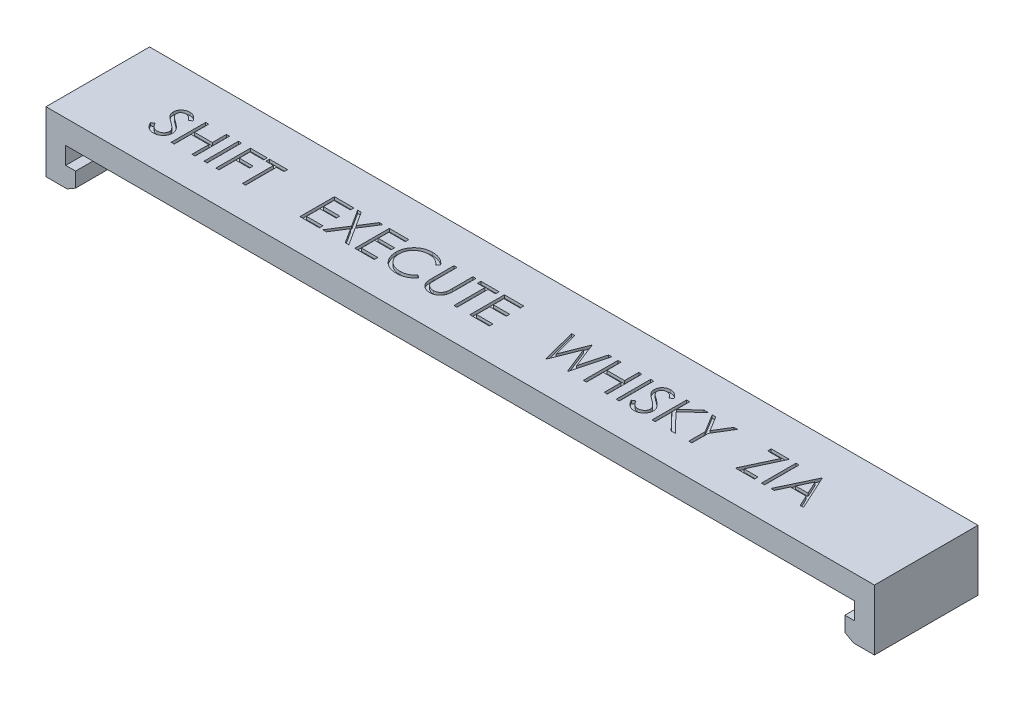
from build123d import *

# Parameters (mm, degrees)
SKETCH1_W             = 80
SKETCH1_H             = 10.5
BOSS_EXTRUDE1_DEPTH   = 2.4
SKETCH2_W             = 10.5
SKETCH2_H             = 4.15
BOSS_EXTRUDE2_DEPTH   = 2
SKETCH3_W             = 10.5
SKETCH3_H             = 4.15
BOSS_EXTRUDE3_DEPTH   = 2
SKETCH4_W             = 3
SKETCH4_H             = 10.5
BOSS_EXTRUDE4_DEPTH   = 2
CHAMFER1_SIZE         = 0.5
CHAMFER1_SIZE2        = 0.866025404
CHAMFER1_PART_2_SIZE  = 0.5
CHAMFER1_PART_2_SIZE2 = 0.866025404
SKETCH5_W             = 80
SKETCH5_H             = 6.4
CUT_EXTRUDE1_DEPTH    = 1.7
SKETCH6_W             = 0.314102564
SKETCH6_H             = 3.5
CUT_EXTRUDE2_DEPTH    = 0.3


with BuildPart() as part:
    # Sketch1 → Boss-Extrude1 (new body)
    with BuildSketch(Plane(origin=(0, 0, 0), x_dir=(1, 0, 0), z_dir=(0, 1, 0))):
        Rectangle(SKETCH1_W, SKETCH1_H)
    extrude(amount=BOSS_EXTRUDE1_DEPTH)

    # Sketch2 → Boss-Extrude2 (add)
    with BuildSketch(Plane(origin=(40, 0, 0), x_dir=(0, 0, -1), z_dir=(1, 0, 0))):
        with Locations((0, 0.325)):
            Rectangle(SKETCH2_W, SKETCH2_H)
    extrude(amount=BOSS_EXTRUDE2_DEPTH)

    # Sketch3 → Boss-Extrude3 (add)
    with BuildSketch(Plane.ZY.offset(40)):
        with Locations((0, 0.325)):
            Rectangle(SKETCH3_W, SKETCH3_H)
    extrude(amount=BOSS_EXTRUDE3_DEPTH)

    # Sketch4 → Boss-Extrude4 (add)
    with BuildSketch(Plane.XZ.offset(1.75)):
        with Locations((-40.5, 0)):
            Rectangle(SKETCH4_W, SKETCH4_H)
        with Locations((40.5, 0)):
            Rectangle(SKETCH4_W, SKETCH4_H)
    extrude(amount=BOSS_EXTRUDE4_DEPTH)

    # Chamfer1
    chamfer1_edges = [part.edges().sort_by_distance(p)[0] for p in [
        (-39, -3.75, 0),
    ]]
    chamfer1_side = [part.faces().sort_by_distance(p)[0] for p in [
        (-39, -2.75, 0),
    ]]
    chamfer(chamfer1_edges, length=CHAMFER1_SIZE, length2=CHAMFER1_SIZE2, reference=chamfer1_side[0])

    # Chamfer1 part 2
    chamfer1_part_2_edges = [part.edges().sort_by_distance(p)[0] for p in [
        (39, -3.75, 0),
    ]]
    chamfer1_part_2_side = [part.faces().sort_by_distance(p)[0] for p in [
        (39, -2.75, 0),
    ]]
    chamfer(chamfer1_part_2_edges, length=CHAMFER1_PART_2_SIZE, length2=CHAMFER1_PART_2_SIZE2, reference=chamfer1_part_2_side[0])

    # Sketch5 → Cut-Extrude1 (cut)
    with BuildSketch(Plane.XZ):
        with Locations((0, -0.25)):
            Rectangle(SKETCH5_W, SKETCH5_H)
    extrude(amount=-CUT_EXTRUDE1_DEPTH, mode=Mode.SUBTRACT)

    # Sketch6 → Cut-Extrude2 (cut)
    with BuildSketch(Plane(origin=(0, 2.4, 0), x_dir=(1, 0, 0), z_dir=(0, 1, 0))):
        with BuildLine():
            Line((-35.314429306, -1.351297613), (-35.018555909, -1.173913799))
            add(Edge.make_bspline(
                [(-35.018555909, -1.173913799), (-34.991037672, -1.219978184), (-34.938313791, -1.308235768), (-34.850362432, -1.427493808), (-34.759229521, -1.528855965), (-34.664240187, -1.611732573), (-34.565974239, -1.676981459), (-34.463790185, -1.723183691), (-34.358032375, -1.751999666), (-34.286058553, -1.755499753), (-34.250126422, -1.757247132)],
                knots=[0, 0, 0, 0, 0.000160901, 0.00030828, 0.000443778, 0.00056903, 0.000685513, 0.000796284, 0.00090427, 0.001011928, 0.001011928, 0.001011928, 0.001011928], degree=3))
            add(Edge.make_bspline(
                [(-34.250126422, -1.757247132), (-34.219439561, -1.75639246), (-34.158602788, -1.75469807), (-34.069040545, -1.738417267), (-33.982058743, -1.713405139), (-33.899450105, -1.677584207), (-33.822354491, -1.634245721), (-33.754747795, -1.581899544), (-33.696301682, -1.523293338), (-33.648492568, -1.457910683), (-33.611812532, -1.387593535), (-33.583620464, -1.315417584), (-33.56797539, -1.240249015), (-33.565618637, -1.189638552), (-33.564429306, -1.164098094)],
                knots=[0, 0, 0, 0, 9.1978e-05, 0.000182347, 0.000272202, 0.000362975, 0.000451852, 0.000536835, 0.000618639, 0.000699414, 0.000778765, 0.000855983, 0.0009312, 0.001007828, 0.001007828, 0.001007828, 0.001007828], degree=3))
            add(Edge.make_bspline(
                [(-33.564429306, -1.164098094), (-33.565903617, -1.134957244), (-33.568900675, -1.075718155), (-33.594232155, -0.988318502), (-33.634081402, -0.901825932), (-33.670844046, -0.848324666), (-33.689930108, -0.820548414)],
                knots=[0, 0, 0, 0, 8.7281e-05, 0.000177429, 0.000270909, 0.000371844, 0.000371844, 0.000371844, 0.000371844], degree=3))
            add(Edge.make_bspline(
                [(-33.689930108, -0.820548414), (-33.705600722, -0.800501591), (-33.738499216, -0.758415792), (-33.795056729, -0.695770557), (-33.861422843, -0.631152138), (-33.935326398, -0.562093081), (-34.019459487, -0.491805284), (-34.111187001, -0.416937006), (-34.21285086, -0.340335429), (-34.284150357, -0.288962864), (-34.320939723, -0.262455466)],
                knots=[0, 0, 0, 0, 7.6319e-05, 0.000160223, 0.000252933, 0.000354147, 0.000463581, 0.000581729, 0.000709336, 0.000845369, 0.000845369, 0.000845369, 0.000845369], degree=3))
            add(Edge.make_bspline(
                [(-34.320939723, -0.262455466), (-34.357763719, -0.236226878), (-34.428168396, -0.186079816), (-34.526626978, -0.111655532), (-34.614671441, -0.043611662), (-34.691910458, 0.01869235), (-34.758310055, 0.075264955), (-34.814393466, 0.125562894), (-34.858732023, 0.170946455), (-34.883387603, 0.200387796), (-34.894457351, 0.213606233)],
                knots=[0, 0, 0, 0, 0.000135623, 0.000259301, 0.000370234, 0.000469439, 0.00055697, 0.000631911, 0.000695377, 0.00074709, 0.00074709, 0.00074709, 0.00074709], degree=3))
            add(Edge.make_bspline(
                [(-34.894457351, 0.213606233), (-34.909929897, 0.23420727), (-34.940358733, 0.274721974), (-34.980524739, 0.338046831), (-35.014663902, 0.402870097), (-35.041426234, 0.469365961), (-35.063962453, 0.53660089), (-35.079120383, 0.605452136), (-35.08861178, 0.675610754), (-35.089583767, 0.722824255), (-35.090070332, 0.746458797)],
                knots=[0, 0, 0, 0, 7.727e-05, 0.000151962, 0.000224716, 0.000296717, 0.00036678, 0.0004372, 0.000507902, 0.000578771, 0.000578771, 0.000578771, 0.000578771], degree=3))
            add(Edge.make_bspline(
                [(-35.090070332, 0.746458797), (-35.088765123, 0.783488572), (-35.086182603, 0.856756635), (-35.064342086, 0.963787466), (-35.029869192, 1.065973883), (-34.981574304, 1.162304217), (-34.919316951, 1.250270198), (-34.847270977, 1.330883685), (-34.761459491, 1.398652267), (-34.667306867, 1.457864325), (-34.564250495, 1.504210251), (-34.456259592, 1.539171231), (-34.34316252, 1.558980488), (-34.266559385, 1.561823253), (-34.227690524, 1.563265688)],
                knots=[0, 0, 0, 0, 0.000110999, 0.000219625, 0.000326272, 0.00043382, 0.000541574, 0.000648775, 0.000756959, 0.000868438, 0.000981703, 0.00109501, 0.001208203, 0.0013248, 0.0013248, 0.0013248, 0.0013248], degree=3))
            add(Edge.make_bspline(
                [(-34.227690524, 1.563265688), (-34.186446424, 1.561843137), (-34.104425072, 1.559014136), (-33.983775857, 1.534416604), (-33.86761514, 1.493715932), (-33.774171876, 1.447527274), (-33.701039114, 1.401395859), (-33.645266381, 1.359376034), (-33.588748931, 1.311000926), (-33.531030876, 1.25614168), (-33.473090216, 1.194294929), (-33.414066764, 1.12588424), (-33.353822495, 1.051327684), (-33.315066635, 0.998103183), (-33.295198537, 0.970817772)],
                knots=[0, 0, 0, 0, 0.000123638, 0.000245877, 0.000367608, 0.000492088, 0.000557638, 0.000626769, 0.000701372, 0.00078072, 0.000865532, 0.000955497, 0.001051745, 0.001152989, 0.001152989, 0.001152989, 0.001152989], degree=3))
            Line((-33.295198537, 0.970817772), (-33.579152864, 0.755573381))
            add(Edge.make_bspline(
                [(-33.579152864, 0.755573381), (-33.596298797, 0.777662071), (-33.629317854, 0.820199724), (-33.679447341, 0.87977104), (-33.726695988, 0.934187519), (-33.773246388, 0.981452647), (-33.81664002, 1.024154781), (-33.858757062, 1.060714537), (-33.898991413, 1.091490133), (-33.949708324, 1.124333693), (-34.013426042, 1.156890196), (-34.093410578, 1.184439275), (-34.176996853, 1.200994336), (-34.233926485, 1.203183224), (-34.262746614, 1.204291329)],
                knots=[0, 0, 0, 0, 8.3877e-05, 0.000161528, 0.000233552, 0.000299993, 0.000360485, 0.000416152, 0.000467195, 0.000512312, 0.000597287, 0.000681099, 0.000765389, 0.000851809, 0.000851809, 0.000851809, 0.000851809], degree=3))
            add(Edge.make_bspline(
                [(-34.262746614, 1.204291329), (-34.298903137, 1.203079629), (-34.368627584, 1.20074298), (-34.46761782, 1.175222995), (-34.556711745, 1.135041134), (-34.63326431, 1.078726156), (-34.697001287, 1.012005164), (-34.743106746, 0.935226309), (-34.770856911, 0.850443906), (-34.77424319, 0.79130225), (-34.775967768, 0.761182355)],
                knots=[0, 0, 0, 0, 0.000108248, 0.000208746, 0.00030443, 0.000399793, 0.000492054, 0.00057947, 0.000666386, 0.000756591, 0.000756591, 0.000756591, 0.000756591], degree=3))
            add(Edge.make_bspline(
                [(-34.775967768, 0.761182355), (-34.775574641, 0.742430876), (-34.774787745, 0.704897257), (-34.763812948, 0.649445835), (-34.749713619, 0.594134496), (-34.727370987, 0.539211913), (-34.696525683, 0.483717554), (-34.656020507, 0.426695816), (-34.605007195, 0.367644107), (-34.565930183, 0.329236734), (-34.545298697, 0.308958797)],
                knots=[0, 0, 0, 0, 5.616e-05, 0.000112411, 0.000169046, 0.000227244, 0.000289691, 0.000359134, 0.000436702, 0.000523463, 0.000523463, 0.000523463, 0.000523463], degree=3))
            add(Edge.make_bspline(
                [(-34.545298697, 0.308958797), (-34.537637325, 0.302121771), (-34.519435658, 0.285878563), (-34.486159732, 0.259286282), (-34.442216934, 0.22648351), (-34.388754733, 0.185896194), (-34.324787371, 0.138814732), (-34.250307815, 0.085841119), (-34.166146282, 0.02525566), (-34.106424366, -0.01710188), (-34.074845973, -0.039498735)],
                knots=[0, 0, 0, 0, 3.0802e-05, 7.3177e-05, 0.000127725, 0.000195314, 0.000274544, 0.000365991, 0.000469501, 0.000585644, 0.000585644, 0.000585644, 0.000585644], degree=3))
            add(Edge.make_bspline(
                [(-34.074845973, -0.039498735), (-34.03686006, -0.067140094), (-33.963305603, -0.120663756), (-33.858648024, -0.201079436), (-33.763754215, -0.279727205), (-33.678291012, -0.356104812), (-33.601414103, -0.429632905), (-33.533976383, -0.501196085), (-33.475290702, -0.570281658), (-33.412111484, -0.658854234), (-33.347553664, -0.767635318), (-33.292112157, -0.900913556), (-33.25715381, -1.034709877), (-33.252582294, -1.124636713), (-33.250326742, -1.169005946)],
                knots=[0, 0, 0, 0, 0.000140932, 0.000272896, 0.000395881, 0.000510584, 0.000616697, 0.000714904, 0.000805482, 0.000888372, 0.001041088, 0.001183793, 0.001320341, 0.001453327, 0.001453327, 0.001453327, 0.001453327], degree=3))
            add(Edge.make_bspline(
                [(-33.250326742, -1.169005946), (-33.25098388, -1.200384312), (-33.252285396, -1.262531695), (-33.267246309, -1.353786772), (-33.289165975, -1.442417642), (-33.322203208, -1.527328754), (-33.362526367, -1.610073517), (-33.413692615, -1.688481417), (-33.473000299, -1.764287816), (-33.541034064, -1.835471307), (-33.615479967, -1.900817503), (-33.694163661, -1.958946565), (-33.777213934, -2.007414888), (-33.864180251, -2.04696573), (-33.955082588, -2.077899248), (-34.049890371, -2.100312117), (-34.148759883, -2.114067828), (-34.215960364, -2.115495589), (-34.250126422, -2.116221491)],
                knots=[0, 0, 0, 0, 9.4044e-05, 0.000186263, 0.000276729, 0.000367488, 0.000459046, 0.000552398, 0.000647774, 0.000747454, 0.000847311, 0.000944634, 0.001040472, 0.001135227, 0.001230788, 0.001328063, 0.00142712, 0.00152957, 0.00152957, 0.00152957, 0.00152957], degree=3))
            add(Edge.make_bspline(
                [(-34.250126422, -2.116221491), (-34.276561765, -2.11571031), (-34.329099525, -2.114694384), (-34.406809007, -2.105713104), (-34.482948596, -2.093006), (-34.556562878, -2.07283193), (-34.62860029, -2.048354953), (-34.698747524, -2.018216621), (-34.767038578, -1.982099419), (-34.833856161, -1.940804395), (-34.899030335, -1.89274665), (-34.961949803, -1.836773154), (-35.024678989, -1.774427649), (-35.085366385, -1.704017085), (-35.14523953, -1.626679002), (-35.203117939, -1.541689819), (-35.260199657, -1.449512465), (-35.296015125, -1.384647379), (-35.314429306, -1.351297613)],
                knots=[0, 0, 0, 0, 7.9276e-05, 0.000157554, 0.000234438, 0.000310629, 0.000386236, 0.000462555, 0.000539392, 0.000617798, 0.000698008, 0.000781971, 0.000870217, 0.00096315, 0.001060616, 0.001163492, 0.001271478, 0.00138575, 0.00138575, 0.00138575, 0.00138575], degree=3))
        make_face()
        Polygon((-32.532378024, 1.473522098), (-32.21827546, 1.473522098), (-32.21827546, 0.037624663), (-30.423403665, 0.037624663), (-30.423403665, 1.473522098), (-30.109301101, 1.473522098), (-30.109301101, -2.026477902), (-30.423403665, -2.026477902), (-30.423403665, -0.321349696), (-32.21827546, -0.321349696), (-32.21827546, -2.026477902), (-32.532378024, -2.026477902), align=None)
        with Locations((-29.054813922, -0.276477902)):
            Rectangle(SKETCH6_W, SKETCH6_H)
        Polygon((-28.000326742, 1.473522098), (-26.295198537, 1.473522098), (-26.295198537, 1.114547739), (-27.686224178, 1.114547739), (-27.686224178, 0.037624663), (-26.295198537, 0.037624663), (-26.295198537, -0.321349696), (-27.686224178, -0.321349696), (-27.686224178, -2.026477902), (-28.000326742, -2.026477902), align=None)
        Polygon((-26.070839563, 1.114547739), (-26.070839563, 1.473522098), (-24.231095973, 1.473522098), (-24.231095973, 1.114547739), (-24.993916486, 1.114547739), (-24.993916486, -2.026477902), (-25.30801905, -2.026477902), (-25.30801905, 1.114547739), align=None)
        Polygon((-19.478016769, 1.473522098), (-17.503657795, 1.473522098), (-17.503657795, 1.114547739), (-19.163914205, 1.114547739), (-19.163914205, 0.037624663), (-17.503657795, 0.037624663), (-17.503657795, -0.321349696), (-19.163914205, -0.321349696), (-19.163914205, -1.667503543), (-17.503657795, -1.667503543), (-17.503657795, -2.026477902), (-19.478016769, -2.026477902), align=None)
        Polygon((-17.122247539, 1.473522098), (-16.759767571, 1.473522098), (-15.843401385, 0.041831393), (-14.927035199, 1.473522098), (-14.564555231, 1.473522098), (-15.66181084, -0.241421812), (-14.519683436, -2.026477902), (-14.882163404, -2.026477902), (-15.843401385, -0.524675017), (-16.804639365, -2.026477902), (-17.167119333, -2.026477902), (-16.024290808, -0.241421812), align=None)
        Polygon((-13.913914205, 1.473522098), (-11.939555231, 1.473522098), (-11.939555231, 1.114547739), (-13.599811641, 1.114547739), (-13.599811641, 0.037624663), (-11.939555231, 0.037624663), (-11.939555231, -0.321349696), (-13.599811641, -0.321349696), (-13.599811641, -1.667503543), (-11.939555231, -1.667503543), (-11.939555231, -2.026477902), (-13.913914205, -2.026477902), align=None)
        with BuildLine():
            Line((-8.080580872, 0.831294534), (-8.355420615, 0.620957996))
            add(Edge.make_bspline(
                [(-8.355420615, 0.620957996), (-8.375026504, 0.644323966), (-8.413973951, 0.690740881), (-8.476633153, 0.755920426), (-8.541934796, 0.816985687), (-8.609853917, 0.874227567), (-8.681613037, 0.925644333), (-8.755473835, 0.973915436), (-8.832671881, 1.017183174), (-8.939423615, 1.06964616), (-9.079071464, 1.124392315), (-9.254866303, 1.170295546), (-9.438377401, 1.199516722), (-9.563575001, 1.202681563), (-9.627255551, 1.204291329)],
                knots=[0, 0, 0, 0, 9.1485e-05, 0.000181737, 0.000271024, 0.000359627, 0.000447979, 0.000535687, 0.000624217, 0.000713268, 0.000892422, 0.00107303, 0.001257466, 0.001448389, 0.001448389, 0.001448389, 0.001448389], degree=3))
            add(Edge.make_bspline(
                [(-9.627255551, 1.204291329), (-9.662338851, 1.203887367), (-9.732179843, 1.203083191), (-9.835828317, 1.192474066), (-9.937541368, 1.177562856), (-10.037252834, 1.155437532), (-10.134835793, 1.127464913), (-10.230928195, 1.094039499), (-10.324138795, 1.05268466), (-10.415757033, 1.0069764), (-10.503536244, 0.955348955), (-10.586591292, 0.899035603), (-10.664619259, 0.838666507), (-10.737681872, 0.7740154), (-10.80585382, 0.70537344), (-10.868641131, 0.632009098), (-10.925826541, 0.554156925), (-10.978543566, 0.472843517), (-11.025756299, 0.388305725), (-11.065286179, 0.300230655), (-11.100291301, 0.210126552), (-11.127990544, 0.116975391), (-11.14991506, 0.021432625), (-11.165042724, -0.076758163), (-11.175531195, -0.177391842), (-11.176331372, -0.245601155), (-11.176734718, -0.279983511)],
                knots=[0, 0, 0, 0, 0.000105206, 0.000209435, 0.000312261, 0.00041348, 0.000515565, 0.000616682, 0.000718413, 0.000821258, 0.000923708, 0.001023662, 0.001122111, 0.001219464, 0.00131614, 0.001412112, 0.001508869, 0.001605718, 0.001702691, 0.001799013, 0.001895107, 0.001992482, 0.002090281, 0.00218895, 0.002290387, 0.00239349, 0.00239349, 0.00239349, 0.00239349], degree=3))
            add(Edge.make_bspline(
                [(-11.176734718, -0.279983511), (-11.175472899, -0.33171483), (-11.172995485, -0.433282415), (-11.150947151, -0.582053026), (-11.117442059, -0.7245737), (-11.067226482, -0.859953542), (-11.005307432, -0.9898619), (-10.92706682, -1.112100753), (-10.836450283, -1.228517318), (-10.732175864, -1.336360266), (-10.617770048, -1.434873991), (-10.495022136, -1.521624572), (-10.364237848, -1.593939455), (-10.226861218, -1.654115401), (-10.081835104, -1.700372129), (-9.929420302, -1.732936253), (-9.769948306, -1.754178433), (-9.660978907, -1.756212121), (-9.605520776, -1.757247132)],
                knots=[0, 0, 0, 0, 0.000155106, 0.000304531, 0.000450265, 0.000593548, 0.000736853, 0.000881182, 0.001028026, 0.001178769, 0.001330408, 0.001480379, 0.001628835, 0.001777978, 0.001929641, 0.002084627, 0.002245075, 0.00241136, 0.00241136, 0.00241136, 0.00241136], degree=3))
            add(Edge.make_bspline(
                [(-9.605520776, -1.757247132), (-9.544418087, -1.755558353), (-9.424153378, -1.75223443), (-9.247785351, -1.724075181), (-9.078949586, -1.678417263), (-8.917636999, -1.614519341), (-8.764302353, -1.531454053), (-8.618705693, -1.430756175), (-8.480724122, -1.311467843), (-8.39775284, -1.220384714), (-8.355420615, -1.173913799)],
                knots=[0, 0, 0, 0, 0.00018322, 0.00036062, 0.000534275, 0.000707044, 0.000879893, 0.001056289, 0.001237208, 0.001425665, 0.001425665, 0.001425665, 0.001425665], degree=3))
            Line((-8.355420615, -1.173913799), (-8.080580872, -1.382146972))
            add(Edge.make_bspline(
                [(-8.080580872, -1.382146972), (-8.102698982, -1.410685424), (-8.146829257, -1.46762563), (-8.218287274, -1.54789734), (-8.293564571, -1.623401375), (-8.373220281, -1.693528997), (-8.456338073, -1.759683462), (-8.544410385, -1.819985294), (-8.636279418, -1.875276178), (-8.731633897, -1.925903102), (-8.83037251, -1.970820349), (-8.932376945, -2.009274117), (-9.03720752, -2.042399007), (-9.144869028, -2.069650943), (-9.255584785, -2.090922027), (-9.368955259, -2.105141702), (-9.485225135, -2.114883617), (-9.563666556, -2.115771532), (-9.60341741, -2.116221491)],
                knots=[0, 0, 0, 0, 0.000108293, 0.000216068, 0.000322162, 0.000427957, 0.000534281, 0.00064066, 0.000747915, 0.000855806, 0.000964371, 0.001073102, 0.001182643, 0.001294024, 0.001406092, 0.001520624, 0.001636667, 0.001755891, 0.001755891, 0.001755891, 0.001755891], degree=3))
            add(Edge.make_bspline(
                [(-9.60341741, -2.116221491), (-9.641061077, -2.115959499), (-9.715496768, -2.115441441), (-9.825395519, -2.107049273), (-9.9323851, -2.095599537), (-10.036159726, -2.078359406), (-10.137285701, -2.058015065), (-10.234846285, -2.030743809), (-10.329801496, -2.000194642), (-10.421769836, -1.964289655), (-10.510829536, -1.923773473), (-10.596693348, -1.877981914), (-10.67932178, -1.827300049), (-10.759527201, -1.772845039), (-10.836124784, -1.712867737), (-10.90977831, -1.648201103), (-10.980900786, -1.579063092), (-11.024903471, -1.529208238), (-11.047027186, -1.504142164)],
                knots=[0, 0, 0, 0, 0.0001129, 0.000223246, 0.000330481, 0.000435603, 0.000538732, 0.000639764, 0.000739316, 0.000837878, 0.000935767, 0.001032686, 0.001129604, 0.00122645, 0.001323362, 0.001421241, 0.001520399, 0.001620667, 0.001620667, 0.001620667, 0.001620667], degree=3))
            add(Edge.make_bspline(
                [(-11.047027186, -1.504142164), (-11.082462829, -1.460600975), (-11.152906306, -1.374044265), (-11.24303199, -1.233758284), (-11.320179545, -1.087290075), (-11.382555466, -0.933870146), (-11.431318199, -0.773842759), (-11.465099394, -0.607127244), (-11.487050999, -0.433879302), (-11.489561287, -0.316042514), (-11.490837282, -0.256145369)],
                knots=[0, 0, 0, 0, 0.000168306, 0.00033458, 0.000499224, 0.000664315, 0.00083066, 0.00100034, 0.001174094, 0.001353718, 0.001353718, 0.001353718, 0.001353718], degree=3))
            add(Edge.make_bspline(
                [(-11.490837282, -0.256145369), (-11.489282089, -0.193189916), (-11.486222342, -0.069328991), (-11.460226547, 0.112444962), (-11.418407751, 0.286596361), (-11.359010862, 0.452800105), (-11.283705511, 0.611930386), (-11.190678897, 0.76277159), (-11.081011755, 0.90628839), (-10.955564187, 1.040303141), (-10.817996852, 1.162842494), (-10.670678038, 1.270648698), (-10.513896091, 1.360366214), (-10.349378239, 1.435362376), (-10.175892558, 1.493006839), (-9.993809189, 1.533360026), (-9.803470274, 1.558477142), (-9.673607848, 1.56165235), (-9.607624141, 1.563265688)],
                knots=[0, 0, 0, 0, 0.000188789, 0.000371431, 0.000549644, 0.000725278, 0.00089996, 0.001076844, 0.001255917, 0.001440951, 0.001626689, 0.001807878, 0.001987546, 0.002167657, 0.002349462, 0.002534866, 0.002726448, 0.002924344, 0.002924344, 0.002924344, 0.002924344], degree=3))
            add(Edge.make_bspline(
                [(-9.607624141, 1.563265688), (-9.567409669, 1.56278355), (-9.487809172, 1.561829206), (-9.370056519, 1.552523064), (-9.255414193, 1.537009458), (-9.14380321, 1.515893388), (-9.034680594, 1.489686066), (-8.928880353, 1.455545768), (-8.825781667, 1.416509237), (-8.726034758, 1.371550771), (-8.630118208, 1.321084029), (-8.53806189, 1.265668406), (-8.450597031, 1.2053726), (-8.367108183, 1.140709425), (-8.288991971, 1.070310866), (-8.214030493, 0.99611327), (-8.144769415, 0.915979446), (-8.10201622, 0.859574512), (-8.080580872, 0.831294534)],
                knots=[0, 0, 0, 0, 0.000120626, 0.000238766, 0.000354085, 0.000467531, 0.000579423, 0.000690512, 0.000800803, 0.000910007, 0.001018518, 0.001125773, 0.001232152, 0.001337058, 0.001442329, 0.001547432, 0.001653292, 0.001759736, 0.001759736, 0.001759736, 0.001759736], degree=3))
        make_face()
        with BuildLine():
            Line((-7.362632154, 1.473522098), (-7.04852959, 1.473522098))
            Line((-7.04852959, 1.473522098), (-7.04852959, -0.62353319))
            add(Edge.make_bspline(
                [(-7.04852959, -0.62353319), (-7.048576334, -0.653213926), (-7.048665039, -0.709538237), (-7.048072525, -0.789706537), (-7.046413156, -0.860978996), (-7.045366997, -0.923630344), (-7.043039663, -0.977373091), (-7.041141616, -1.022498402), (-7.03870106, -1.058792604), (-7.035767942, -1.07997353), (-7.034507154, -1.089078062)],
                knots=[0, 0, 0, 0, 8.9042e-05, 0.000168973, 0.000240502, 0.000302917, 0.000356945, 0.000401866, 0.000438432, 0.000465999, 0.000465999, 0.000465999, 0.000465999], degree=3))
            add(Edge.make_bspline(
                [(-7.034507154, -1.089078062), (-7.029329695, -1.121924825), (-7.019266509, -1.185767554), (-6.993620131, -1.276675836), (-6.95780263, -1.358607294), (-6.915359587, -1.434118586), (-6.859426976, -1.501107946), (-6.792423441, -1.562819598), (-6.711245672, -1.616791403), (-6.620985066, -1.666142215), (-6.523699829, -1.705807297), (-6.424288563, -1.735800662), (-6.324245583, -1.754079561), (-6.257269418, -1.7561961), (-6.224010359, -1.757247132)],
                knots=[0, 0, 0, 0, 9.971e-05, 0.000193801, 0.000282365, 0.000367504, 0.000452699, 0.000543015, 0.000639862, 0.000744331, 0.000851226, 0.000954377, 0.001055468, 0.001155185, 0.001155185, 0.001155185, 0.001155185], degree=3))
            add(Edge.make_bspline(
                [(-6.224010359, -1.757247132), (-6.195456619, -1.756173282), (-6.138514057, -1.754031784), (-6.053907626, -1.740770353), (-5.971507517, -1.716869787), (-5.890906838, -1.686030029), (-5.815355853, -1.645282438), (-5.744812411, -1.598211598), (-5.681848477, -1.543000722), (-5.624390479, -1.481900377), (-5.574355543, -1.412960578), (-5.530984402, -1.337682439), (-5.495458472, -1.254933093), (-5.477914947, -1.19677867), (-5.468902186, -1.166902581)],
                knots=[0, 0, 0, 0, 8.5678e-05, 0.00017086, 0.000256092, 0.000342674, 0.000429242, 0.000513055, 0.000596556, 0.000679898, 0.000764179, 0.00085149, 0.000940054, 0.001033621, 0.001033621, 0.001033621, 0.001033621], degree=3))
            add(Edge.make_bspline(
                [(-5.468902186, -1.166902581), (-5.465902061, -1.154554007), (-5.459216572, -1.127036407), (-5.452969528, -1.080515116), (-5.446463002, -1.025625752), (-5.441948432, -0.961973939), (-5.437547212, -0.889772967), (-5.434914139, -0.808646709), (-5.433697106, -0.718889748), (-5.433334426, -0.656252587), (-5.433144974, -0.62353319)],
                knots=[0, 0, 0, 0, 3.81e-05, 8.4902e-05, 0.000140649, 0.000203941, 0.000276279, 0.000357657, 0.000447412, 0.000545571, 0.000545571, 0.000545571, 0.000545571], degree=3))
            Line((-5.433144974, -0.62353319), (-5.433144974, 1.473522098))
            Line((-5.433144974, 1.473522098), (-5.11904241, 1.473522098))
            Line((-5.11904241, 1.473522098), (-5.11904241, -0.640360113))
            add(Edge.make_bspline(
                [(-5.11904241, -0.640360113), (-5.119296531, -0.678458492), (-5.119792462, -0.752809795), (-5.124093039, -0.861761154), (-5.130950038, -0.965114135), (-5.140638126, -1.062882632), (-5.15347513, -1.154716791), (-5.16775035, -1.241421559), (-5.185929883, -1.322374552), (-5.207163284, -1.398206969), (-5.231436832, -1.470392483), (-5.262877981, -1.538901098), (-5.298302481, -1.605815497), (-5.340317134, -1.670123606), (-5.387528516, -1.732110159), (-5.440980197, -1.791399234), (-5.498904358, -1.848938281), (-5.562263917, -1.903251347), (-5.630014443, -1.953060024), (-5.7019544, -1.996857795), (-5.77753117, -2.033881412), (-5.856548296, -2.064357337), (-5.939039499, -2.087271936), (-6.025006859, -2.104347091), (-6.114646052, -2.114049389), (-6.175610708, -2.115491319), (-6.206482314, -2.116221491)],
                knots=[0, 0, 0, 0, 0.000114291, 0.000223047, 0.000327049, 0.000424998, 0.000517708, 0.000605194, 0.000688542, 0.000766455, 0.0008414, 0.000916717, 0.000992315, 0.001068354, 0.001146882, 0.001225836, 0.001307639, 0.001391671, 0.001475952, 0.001559641, 0.001643989, 0.001728103, 0.001813335, 0.001900511, 0.00199079, 0.002083404, 0.002083404, 0.002083404, 0.002083404], degree=3))
            add(Edge.make_bspline(
                [(-6.206482314, -2.116221491), (-6.240151417, -2.115436726), (-6.306210076, -2.113897019), (-6.403548143, -2.105074269), (-6.496862339, -2.088455875), (-6.587138216, -2.067295931), (-6.673146713, -2.038112194), (-6.756040158, -2.004014069), (-6.834398839, -1.962136809), (-6.909493968, -1.915543416), (-6.979318724, -1.863118778), (-7.043416127, -1.805978604), (-7.101891997, -1.745038226), (-7.153760694, -1.67963786), (-7.199881578, -1.610286153), (-7.239611792, -1.536786914), (-7.273725036, -1.459168598), (-7.291331603, -1.405215397), (-7.300232314, -1.377940241)],
                knots=[0, 0, 0, 0, 0.000101022, 0.000198206, 0.000292839, 0.000385177, 0.00047608, 0.000565014, 0.000653769, 0.000742283, 0.000829923, 0.000915339, 0.000999643, 0.001082971, 0.00116542, 0.001249186, 0.001333332, 0.001419362, 0.001419362, 0.001419362, 0.001419362], degree=3))
            add(Edge.make_bspline(
                [(-7.300232314, -1.377940241), (-7.305409472, -1.359307667), (-7.316638844, -1.318893198), (-7.328664141, -1.252006709), (-7.338773223, -1.174991792), (-7.348278781, -1.087843173), (-7.353887739, -0.990493307), (-7.358805178, -0.882984391), (-7.362666797, -0.765186429), (-7.362644024, -0.683131914), (-7.362632154, -0.640360113)],
                knots=[0, 0, 0, 0, 5.799e-05, 0.000125782, 0.000203619, 0.000291034, 0.000388694, 0.000496078, 0.000613919, 0.000742226, 0.000742226, 0.000742226, 0.000742226], degree=3))
            Line((-7.362632154, -0.640360113), (-7.362632154, 1.473522098))
        make_face()
        Polygon((-4.625452667, 1.114547739), (-4.625452667, 1.473522098), (-2.785709077, 1.473522098), (-2.785709077, 1.114547739), (-3.54852959, 1.114547739), (-3.54852959, -2.026477902), (-3.862632154, -2.026477902), (-3.862632154, 1.114547739), align=None)
        Polygon((-2.247247539, 1.473522098), (-0.272888564, 1.473522098), (-0.272888564, 1.114547739), (-1.933144974, 1.114547739), (-1.933144974, 0.037624663), (-0.272888564, 0.037624663), (-0.272888564, -0.321349696), (-1.933144974, -0.321349696), (-1.933144974, -1.667503543), (-0.272888564, -1.667503543), (-0.272888564, -2.026477902), (-2.247247539, -2.026477902), align=None)
        Polygon((4.558705227, 1.473522098), (4.883324618, 1.473522098), (5.568320611, -1.093284793), (6.587050579, 1.473522098), (6.632623496, 1.473522098), (7.632423175, -1.075756748), (8.320924778, 1.473522098), (8.64203856, 1.473522098), (7.698328624, -2.026477902), (7.653456829, -2.026477902), (6.600371893, 0.650405111), (5.534666765, -2.026477902), (5.48979497, -2.026477902), align=None)
        Polygon((9.270243688, 1.473522098), (9.584346252, 1.473522098), (9.584346252, 0.037624663), (11.379218047, 0.037624663), (11.379218047, 1.473522098), (11.693320611, 1.473522098), (11.693320611, -2.026477902), (11.379218047, -2.026477902), (11.379218047, -0.321349696), (9.584346252, -0.321349696), (9.584346252, -2.026477902), (9.270243688, -2.026477902), align=None)
        with Locations((12.747807791, -0.276477902)):
            Rectangle(SKETCH6_W, SKETCH6_H)
        with BuildLine():
            Line((13.443320611, -1.351297613), (13.739194009, -1.173913799))
            add(Edge.make_bspline(
                [(13.739194009, -1.173913799), (13.766712246, -1.219978184), (13.819436127, -1.308235768), (13.907387486, -1.427493808), (13.998520397, -1.528855965), (14.09350973, -1.611732573), (14.191775679, -1.676981459), (14.293959732, -1.723183691), (14.399717543, -1.751999666), (14.471691364, -1.755499753), (14.507623496, -1.757247132)],
                knots=[0, 0, 0, 0, 0.000160901, 0.00030828, 0.000443778, 0.00056903, 0.000685513, 0.000796284, 0.00090427, 0.001011928, 0.001011928, 0.001011928, 0.001011928], degree=3))
            add(Edge.make_bspline(
                [(14.507623496, -1.757247132), (14.538310356, -1.75639246), (14.599147129, -1.75469807), (14.688709372, -1.738417267), (14.775691175, -1.713405139), (14.858299812, -1.677584207), (14.935395427, -1.634245721), (15.003002122, -1.581899544), (15.061448235, -1.523293338), (15.10925735, -1.457910683), (15.145937385, -1.387593535), (15.174129454, -1.315417584), (15.189774527, -1.240249015), (15.192131281, -1.189638552), (15.193320611, -1.164098094)],
                knots=[0, 0, 0, 0, 9.1978e-05, 0.000182347, 0.000272202, 0.000362975, 0.000451852, 0.000536835, 0.000618639, 0.000699414, 0.000778765, 0.000855983, 0.0009312, 0.001007828, 0.001007828, 0.001007828, 0.001007828], degree=3))
            add(Edge.make_bspline(
                [(15.193320611, -1.164098094), (15.191846301, -1.134957244), (15.188849242, -1.075718155), (15.163517762, -0.988318502), (15.123668515, -0.901825932), (15.086905872, -0.848324666), (15.06781981, -0.820548414)],
                knots=[0, 0, 0, 0, 8.7281e-05, 0.000177429, 0.000270909, 0.000371844, 0.000371844, 0.000371844, 0.000371844], degree=3))
            add(Edge.make_bspline(
                [(15.06781981, -0.820548414), (15.052149196, -0.800501591), (15.019250701, -0.758415792), (14.962693189, -0.695770557), (14.896327075, -0.631152138), (14.82242352, -0.562093081), (14.738290431, -0.491805284), (14.646562916, -0.416937006), (14.544899057, -0.340335429), (14.473599561, -0.288962864), (14.436810195, -0.262455466)],
                knots=[0, 0, 0, 0, 7.6319e-05, 0.000160223, 0.000252933, 0.000354147, 0.000463581, 0.000581729, 0.000709336, 0.000845369, 0.000845369, 0.000845369, 0.000845369], degree=3))
            add(Edge.make_bspline(
                [(14.436810195, -0.262455466), (14.399986198, -0.236226878), (14.329581522, -0.186079816), (14.231122939, -0.111655532), (14.143078476, -0.043611662), (14.06583946, 0.01869235), (13.999439863, 0.075264955), (13.943356452, 0.125562894), (13.899017895, 0.170946455), (13.874362314, 0.200387796), (13.863292566, 0.213606233)],
                knots=[0, 0, 0, 0, 0.000135623, 0.000259301, 0.000370234, 0.000469439, 0.00055697, 0.000631911, 0.000695377, 0.00074709, 0.00074709, 0.00074709, 0.00074709], degree=3))
            add(Edge.make_bspline(
                [(13.863292566, 0.213606233), (13.847820021, 0.23420727), (13.817391184, 0.274721974), (13.777225179, 0.338046831), (13.743086016, 0.402870097), (13.716323684, 0.469365961), (13.693787465, 0.53660089), (13.678629534, 0.605452136), (13.669138138, 0.675610754), (13.668166151, 0.722824255), (13.667679586, 0.746458797)],
                knots=[0, 0, 0, 0, 7.727e-05, 0.000151962, 0.000224716, 0.000296717, 0.00036678, 0.0004372, 0.000507902, 0.000578771, 0.000578771, 0.000578771, 0.000578771], degree=3))
            add(Edge.make_bspline(
                [(13.667679586, 0.746458797), (13.668984795, 0.783488572), (13.671567315, 0.856756635), (13.693407832, 0.963787466), (13.727880726, 1.065973883), (13.776175613, 1.162304217), (13.838432966, 1.250270198), (13.910478941, 1.330883685), (13.996290427, 1.398652267), (14.09044305, 1.457864325), (14.193499422, 1.504210251), (14.301490326, 1.539171231), (14.414587398, 1.558980488), (14.491190532, 1.561823253), (14.530059393, 1.563265688)],
                knots=[0, 0, 0, 0, 0.000110999, 0.000219625, 0.000326272, 0.00043382, 0.000541574, 0.000648775, 0.000756959, 0.000868438, 0.000981703, 0.00109501, 0.001208203, 0.0013248, 0.0013248, 0.0013248, 0.0013248], degree=3))
            add(Edge.make_bspline(
                [(14.530059393, 1.563265688), (14.571303494, 1.561843137), (14.653324845, 1.559014136), (14.773974061, 1.534416604), (14.890134777, 1.493715932), (14.983578042, 1.447527274), (15.056710804, 1.401395859), (15.112483536, 1.359376034), (15.169000987, 1.311000926), (15.226719042, 1.25614168), (15.284659701, 1.194294929), (15.343683154, 1.12588424), (15.403927422, 1.051327684), (15.442683282, 0.998103183), (15.46255138, 0.970817772)],
                knots=[0, 0, 0, 0, 0.000123638, 0.000245877, 0.000367608, 0.000492088, 0.000557638, 0.000626769, 0.000701372, 0.00078072, 0.000865532, 0.000955497, 0.001051745, 0.001152989, 0.001152989, 0.001152989, 0.001152989], degree=3))
            Line((15.46255138, 0.970817772), (15.178597054, 0.755573381))
            add(Edge.make_bspline(
                [(15.178597054, 0.755573381), (15.161451121, 0.777662071), (15.128432064, 0.820199724), (15.078302577, 0.87977104), (15.031053929, 0.934187519), (14.984503529, 0.981452647), (14.941109898, 1.024154781), (14.898992856, 1.060714537), (14.858758504, 1.091490133), (14.808041594, 1.124333693), (14.744323875, 1.156890196), (14.664339339, 1.184439275), (14.580753064, 1.200994336), (14.523823433, 1.203183224), (14.495003304, 1.204291329)],
                knots=[0, 0, 0, 0, 8.3877e-05, 0.000161528, 0.000233552, 0.000299993, 0.000360485, 0.000416152, 0.000467195, 0.000512312, 0.000597287, 0.000681099, 0.000765389, 0.000851809, 0.000851809, 0.000851809, 0.000851809], degree=3))
            add(Edge.make_bspline(
                [(14.495003304, 1.204291329), (14.458846781, 1.203079629), (14.389122334, 1.20074298), (14.290132098, 1.175222995), (14.201038173, 1.135041134), (14.124485607, 1.078726156), (14.06074863, 1.012005164), (14.014643172, 0.935226309), (13.986893007, 0.850443906), (13.983506727, 0.79130225), (13.98178215, 0.761182355)],
                knots=[0, 0, 0, 0, 0.000108248, 0.000208746, 0.00030443, 0.000399793, 0.000492054, 0.00057947, 0.000666386, 0.000756591, 0.000756591, 0.000756591, 0.000756591], degree=3))
            add(Edge.make_bspline(
                [(13.98178215, 0.761182355), (13.982175276, 0.742430876), (13.982962172, 0.704897257), (13.99393697, 0.649445835), (14.008036299, 0.594134496), (14.030378931, 0.539211913), (14.061224234, 0.483717554), (14.10172941, 0.426695816), (14.152742722, 0.367644107), (14.191819735, 0.329236734), (14.21245122, 0.308958797)],
                knots=[0, 0, 0, 0, 5.616e-05, 0.000112411, 0.000169046, 0.000227244, 0.000289691, 0.000359134, 0.000436702, 0.000523463, 0.000523463, 0.000523463, 0.000523463], degree=3))
            add(Edge.make_bspline(
                [(14.21245122, 0.308958797), (14.220112593, 0.302121771), (14.23831426, 0.285878563), (14.271590185, 0.259286282), (14.315532984, 0.22648351), (14.368995185, 0.185896194), (14.432962547, 0.138814732), (14.507442103, 0.085841119), (14.591603636, 0.02525566), (14.651325551, -0.01710188), (14.682903945, -0.039498735)],
                knots=[0, 0, 0, 0, 3.0802e-05, 7.3177e-05, 0.000127725, 0.000195314, 0.000274544, 0.000365991, 0.000469501, 0.000585644, 0.000585644, 0.000585644, 0.000585644], degree=3))
            add(Edge.make_bspline(
                [(14.682903945, -0.039498735), (14.720889858, -0.067140094), (14.794444314, -0.120663756), (14.899101894, -0.201079436), (14.993995702, -0.279727205), (15.079458906, -0.356104812), (15.156335814, -0.429632905), (15.223773535, -0.501196085), (15.282459215, -0.570281658), (15.345638434, -0.658854234), (15.410196253, -0.767635318), (15.465637761, -0.900913556), (15.500596108, -1.034709877), (15.505167624, -1.124636713), (15.507423175, -1.169005946)],
                knots=[0, 0, 0, 0, 0.000140932, 0.000272896, 0.000395881, 0.000510584, 0.000616697, 0.000714904, 0.000805482, 0.000888372, 0.001041088, 0.001183793, 0.001320341, 0.001453327, 0.001453327, 0.001453327, 0.001453327], degree=3))
            add(Edge.make_bspline(
                [(15.507423175, -1.169005946), (15.506766037, -1.200384312), (15.505464522, -1.262531695), (15.490503608, -1.353786772), (15.468583943, -1.442417642), (15.435546709, -1.527328754), (15.395223551, -1.610073517), (15.344057303, -1.688481417), (15.284749618, -1.764287816), (15.216715853, -1.835471307), (15.142269951, -1.900817503), (15.063586256, -1.958946565), (14.980535984, -2.007414888), (14.893569667, -2.04696573), (14.80266733, -2.077899248), (14.707859546, -2.100312117), (14.608990035, -2.114067828), (14.541789554, -2.115495589), (14.507623496, -2.116221491)],
                knots=[0, 0, 0, 0, 9.4044e-05, 0.000186263, 0.000276729, 0.000367488, 0.000459046, 0.000552398, 0.000647774, 0.000747454, 0.000847311, 0.000944634, 0.001040472, 0.001135227, 0.001230788, 0.001328063, 0.00142712, 0.00152957, 0.00152957, 0.00152957, 0.00152957], degree=3))
            add(Edge.make_bspline(
                [(14.507623496, -2.116221491), (14.481188153, -2.11571031), (14.428650393, -2.114694384), (14.350940911, -2.105713104), (14.274801322, -2.093006), (14.20118704, -2.07283193), (14.129149628, -2.048354953), (14.059002394, -2.018216621), (13.99071134, -1.982099419), (13.923893757, -1.940804395), (13.858719582, -1.89274665), (13.795800114, -1.836773154), (13.733070929, -1.774427649), (13.672383532, -1.704017085), (13.612510388, -1.626679002), (13.554631979, -1.541689819), (13.497550261, -1.449512465), (13.461734793, -1.384647379), (13.443320611, -1.351297613)],
                knots=[0, 0, 0, 0, 7.9276e-05, 0.000157554, 0.000234438, 0.000310629, 0.000386236, 0.000462555, 0.000539392, 0.000617798, 0.000698008, 0.000781971, 0.000870217, 0.00096315, 0.001060616, 0.001163492, 0.001271478, 0.00138575, 0.00138575, 0.00138575, 0.00138575], degree=3))
        make_face()
        Polygon((16.225371893, 1.473522098), (16.539474457, 1.473522098), (16.539474457, 0.140689566), (17.998508912, 1.473522098), (18.446525739, 1.473522098), (16.726673977, -0.096990722), (18.581141124, -2.026477902), (18.162571412, -2.026477902), (16.539474457, -0.337475498), (16.539474457, -2.026477902), (16.225371893, -2.026477902), align=None)
        Polygon((18.827935996, 1.473522098), (19.187611477, 1.473522098), (20.107483271, -0.030384152), (21.025952823, 1.473522098), (21.385628304, 1.473522098), (20.263833432, -0.362715882), (20.263833432, -2.026477902), (19.949730868, -2.026477902), (19.949730868, -0.362715882), align=None)
        Polygon((24.811762795, 1.114547739), (24.811762795, 1.473522098), (26.651506385, 1.473522098), (25.183357346, -1.667503543), (26.60663459, -1.667503543), (26.60663459, -2.026477902), (24.67714741, -2.026477902), (26.145296449, 1.114547739), align=None)
        with Locations((27.48163459, -0.276477902)):
            Rectangle(SKETCH6_W, SKETCH6_H)
        Polygon((29.972019205, 1.473522098), (31.58740382, -2.026477902), (31.245957506, -2.026477902), (30.728529622, -0.90468303), (29.141891, -0.90468303), (28.609739558, -2.026477902), (28.266891, -2.026477902), (29.92714741, 1.473522098), align=None)
        Polygon((29.946077699, 0.791330592), (29.312263596, -0.545708671), (30.563064878, -0.545708671), align=None, mode=Mode.SUBTRACT)
    extrude(amount=-CUT_EXTRUDE2_DEPTH, mode=Mode.SUBTRACT)


solid = part.part
